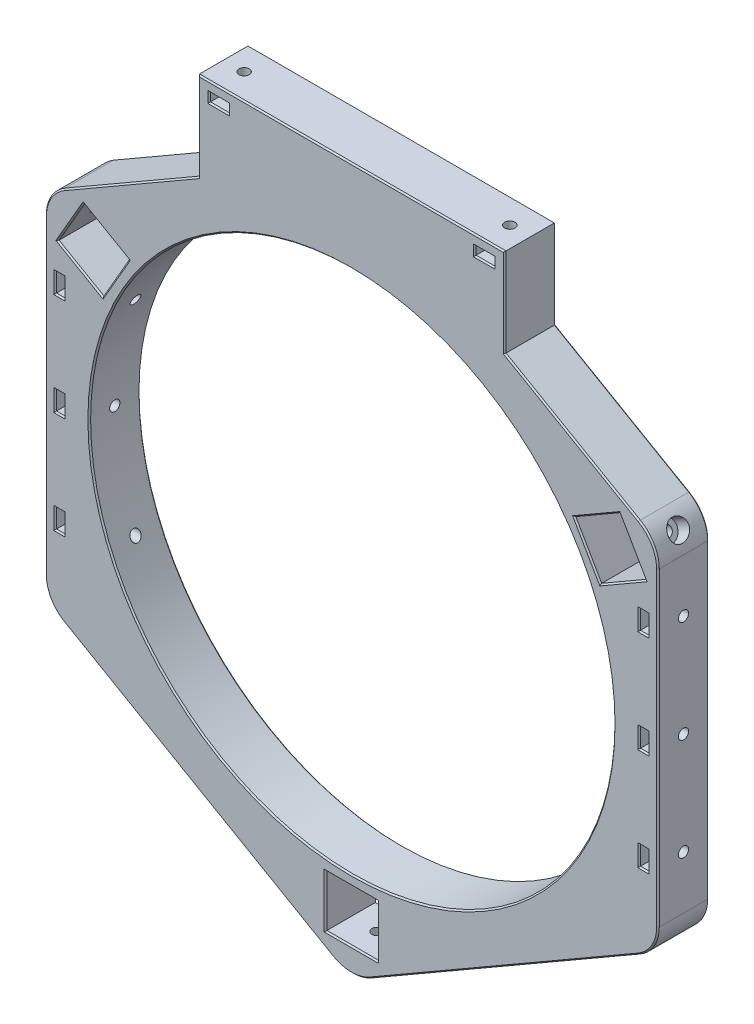
from build123d import *

# Parameters (mm, degrees)
SKETCH1_R           = 77
BOSS_EXTRUDE1_DEPTH = 15
SKETCH2_W           = 15.2
SKETCH2_H           = 15.2
CUT_EXTRUDE1_DEPTH  = 16
FILLET1_R           = 11.11
SKETCH9_R           = 1.5
CUT_EXTRUDE6_DEPTH  = 3
SKETCH10_R          = 3
CUT_EXTRUDE7_DEPTH  = 32.703810568
CIRPATTERN2_COUNT   = 3
SKETCH15_R          = 1.5
CUT_EXTRUDE11_DEPTH = 30
SKETCH16_W          = 5.6
SKETCH16_H          = 2.5
CUT_EXTRUDE12_DEPTH = 16.0000001
SKETCH18_R          = 1.5
CUT_EXTRUDE13_DEPTH = 181.0000001
SKETCH19_W          = 2.5
SKETCH19_H          = 5.6
CUT_EXTRUDE14_DEPTH = 16.0000001
CHAMFER1_SIZE       = 0.4


with BuildPart() as part:
    # Sketch1 → Boss-Extrude1 (new body)
    with BuildSketch(Plane.XY):
        Polygon((45, 77.942286341), (90, 51.961524227), (90, -51.961524227), (0, -103.923048454), (-90, -51.961524227), (-90, 51.961524227), (-45, 77.942286341), (-45, 103.923048454), (45, 103.923048454), align=None)
        Circle(SKETCH1_R, mode=Mode.SUBTRACT)
    extrude(amount=BOSS_EXTRUDE1_DEPTH)

    # Sketch2 → Cut-Extrude1 (cut, through all)
    with BuildSketch(Plane.XY.offset(15)):
        with Locations((0, -87.6)):
            Rectangle(SKETCH2_W, SKETCH2_H)
        Polygon((-65.482032303, 46.581793069), (-73.082032303, 33.418206931), (-86.24561844, 41.018206931), (-78.64561844, 54.181793069), align=None)
        Polygon((73.082032303, 33.418206931), (65.482032303, 46.581793069), (78.64561844, 54.181793069), (86.24561844, 41.018206931), align=None)
    extrude(amount=-CUT_EXTRUDE1_DEPTH, mode=Mode.SUBTRACT)

    # Fillet1
    fillet1_edges = [part.edges().sort_by_distance(p)[0] for p in [
        (0, -103.923048454, 7.5),
        (-90, -51.961524227, 7.5),
        (-90, 51.961524227, 7.5),
        (90, 51.961524227, 7.5),
        (90, -51.961524227, 7.5),
    ]]
    fillet(fillet1_edges, radius=FILLET1_R)

    # Sketch9 → Cut-Extrude6 (cut)
    with BuildSketch(Plane(origin=(-82.44561844, 47.6, 0), x_dir=(0, 0, -1), z_dir=(0.866025404, -0.5, 0))):
        with Locations((-7.5, 0)):
            Circle(SKETCH9_R)
    cut_extrude6 = extrude(amount=-CUT_EXTRUDE6_DEPTH, mode=Mode.SUBTRACT)

    # Sketch10 → Cut-Extrude7 (cut, through all)
    with BuildSketch(Plane(origin=(-85.043694652, 49.1, 0), x_dir=(0, 0, -1), z_dir=(0.866025404, -0.5, 0))):
        with Locations((-7.5, 0)):
            Circle(SKETCH10_R)
    cut_extrude7 = extrude(amount=-CUT_EXTRUDE7_DEPTH, mode=Mode.SUBTRACT)

    # CirPattern2: Cut-Extrude6, Cut-Extrude7 ×3 about axis
    cirpattern2_axis = Axis((0, 0, 0), (0, 0, 1))
    for i in range(1, CIRPATTERN2_COUNT):
        add(cut_extrude6.rotate(cirpattern2_axis, i * 360 / CIRPATTERN2_COUNT), mode=Mode.SUBTRACT)
        add(cut_extrude7.rotate(cirpattern2_axis, i * 360 / CIRPATTERN2_COUNT), mode=Mode.SUBTRACT)

    # Sketch15 → Cut-Extrude11 (cut)
    with BuildSketch(Plane(origin=(0, 103.923048454, 0), x_dir=(1, 0, 0), z_dir=(0, 1, 0))):
        with Locations((-39, -7.5)):
            Circle(SKETCH15_R)
        with Locations((39, -7.5)):
            Circle(SKETCH15_R)
    extrude(amount=-CUT_EXTRUDE11_DEPTH, mode=Mode.SUBTRACT)

    # Sketch16 → Cut-Extrude12 (cut, through all)
    with BuildSketch(Plane.XY.offset(15)):
        with Locations((-39, 99.673048454)):
            Rectangle(SKETCH16_W, SKETCH16_H)
        with Locations((39, 99.673048454)):
            Rectangle(SKETCH16_W, SKETCH16_H)
    extrude(amount=-CUT_EXTRUDE12_DEPTH, mode=Mode.SUBTRACT)

    # Sketch18 → Cut-Extrude13 (cut, through all)
    with BuildSketch(Plane(origin=(90, 0, 0), x_dir=(0, 0, -1), z_dir=(1, 0, 0))):
        with Locations((-7.5, 30)):
            Circle(SKETCH18_R)
        with Locations((-7.5, 0)):
            Circle(SKETCH18_R)
        with Locations((-7.5, -30)):
            Circle(SKETCH18_R)
    extrude(amount=-CUT_EXTRUDE13_DEPTH, mode=Mode.SUBTRACT)

    # Sketch19 → Cut-Extrude14 (cut, through all)
    with BuildSketch(Plane.XY.offset(15)):
        with Locations((-85.75, 30)):
            Rectangle(SKETCH19_W, SKETCH19_H)
        with Locations((-85.75, 0)):
            Rectangle(SKETCH19_W, SKETCH19_H)
        with Locations((-85.75, -30)):
            Rectangle(SKETCH19_W, SKETCH19_H)
        with Locations((85.75, -30)):
            Rectangle(SKETCH19_W, SKETCH19_H)
        with Locations((85.75, 0)):
            Rectangle(SKETCH19_W, SKETCH19_H)
        with Locations((85.75, 30)):
            Rectangle(SKETCH19_W, SKETCH19_H)
    extrude(amount=-CUT_EXTRUDE14_DEPTH, mode=Mode.SUBTRACT)

    # Chamfer1
    chamfer1_edges = [part.edges().sort_by_distance(p)[0] for p in [
        (0, 103.923048454, 0),
        (45, 90.932667397, 0),
        (45, 90.932667397, 15),
        (-39, 100.923048454, 0),
        (-39, 98.423048454, 0),
        (-41.8, 99.673048454, 0),
        (-36.2, 99.673048454, 0),
        (-41.8, 99.673048454, 15),
        (-39, 98.423048454, 15),
        (-36.2, 99.673048454, 15),
        (-39, 100.923048454, 15),
        (0, 103.923048454, 15),
        (39, 100.923048454, 0),
        (39, 98.423048454, 0),
        (41.8, 99.673048454, 0),
        (36.2, 99.673048454, 0),
        (39, 100.923048454, 15),
        (36.2, 99.673048454, 15),
        (39, 98.423048454, 15),
        (41.8, 99.673048454, 15),
        (-45, 90.932667397, 15),
        (-64.7225, 66.555495657, 15),
        (-77, 0, 0),
        (-77, 0, 15),
        (87, 30, 0),
        (84.5, 30, 0),
        (85.75, 32.8, 0),
        (85.75, 27.2, 0),
        (85.75, 32.8, 15),
        (84.5, 30, 15),
        (85.75, 27.2, 15),
        (87, 30, 15),
        (87, 0, 0),
        (84.5, 0, 0),
        (85.75, 2.8, 0),
        (85.75, -2.8, 0),
        (85.75, 2.8, 15),
        (84.5, 0, 15),
        (85.75, -2.8, 15),
        (87, 0, 15),
        (87, -30, 0),
        (84.5, -30, 0),
        (85.75, -32.8, 0),
        (85.75, -27.2, 0),
        (87, -30, 15),
        (85.75, -27.2, 15),
        (84.5, -30, 15),
        (85.75, -32.8, 15),
        (-87, -30, 0),
        (-84.5, -30, 0),
        (-85.75, -32.8, 0),
        (-85.75, -27.2, 0),
        (-85.75, -32.8, 15),
        (-84.5, -30, 15),
        (-85.75, -27.2, 15),
        (-87, -30, 15),
        (-87, 0, 0),
        (-84.5, 0, 0),
        (-85.75, 2.8, 0),
        (-85.75, -2.8, 0),
        (-87, 0, 15),
        (-85.75, -2.8, 15),
        (-84.5, 0, 15),
        (-85.75, 2.8, 15),
        (-87, 30, 0),
        (-84.5, 30, 0),
        (-85.75, 32.8, 0),
        (-85.75, 27.2, 0),
        (-87, 30, 15),
        (-85.75, 27.2, 15),
        (-84.5, 30, 15),
        (-85.75, 32.8, 15),
        (7.6, -87.6, 0),
        (0, -95.2, 0),
        (-7.6, -87.6, 0),
        (0, -80, 0),
        (7.6, -87.6, 15),
        (0, -80, 15),
        (-7.6, -87.6, 15),
        (0, -95.2, 15),
        (-79.663825372, 37.218206931, 0),
        (-82.44561844, 47.6, 0),
        (-72.063825372, 50.381793069, 0),
        (-69.282032303, 40, 0),
        (-79.663825372, 37.218206931, 15),
        (-69.282032303, 40, 15),
        (-72.063825372, 50.381793069, 15),
        (-82.44561844, 47.6, 15),
        (72.063825372, 50.381793069, 0),
        (82.44561844, 47.6, 0),
        (79.663825372, 37.218206931, 0),
        (69.282032303, 40, 0),
        (72.063825372, 50.381793069, 15),
        (69.282032303, 40, 15),
        (79.663825372, 37.218206931, 15),
        (82.44561844, 47.6, 15),
        (-45, -77.942286341, 0),
        (-45, -77.942286341, 15),
        (45, -77.942286341, 0),
        (-90, 0, 0),
        (64.7225, 66.555495657, 0),
        (90, 0, 0),
        (0, -102.204325473, 0),
        (88.511542236, -51.102162736, 0),
        (88.511542236, 51.102162736, 0),
        (-88.511542236, 51.102162736, 0),
        (-88.511542236, -51.102162736, 0),
        (-90, 0, 15),
        (45, -77.942286341, 15),
        (90, 0, 15),
        (64.7225, 66.555495657, 15),
        (0, -102.204325473, 15),
        (88.511542236, -51.102162736, 15),
        (88.511542236, 51.102162736, 15),
        (-88.511542236, 51.102162736, 15),
        (-88.511542236, -51.102162736, 15),
        (-64.7225, 66.555495657, 0),
        (-45, 90.932667397, 0),
    ]]
    chamfer(chamfer1_edges, length=CHAMFER1_SIZE)


solid = part.part
